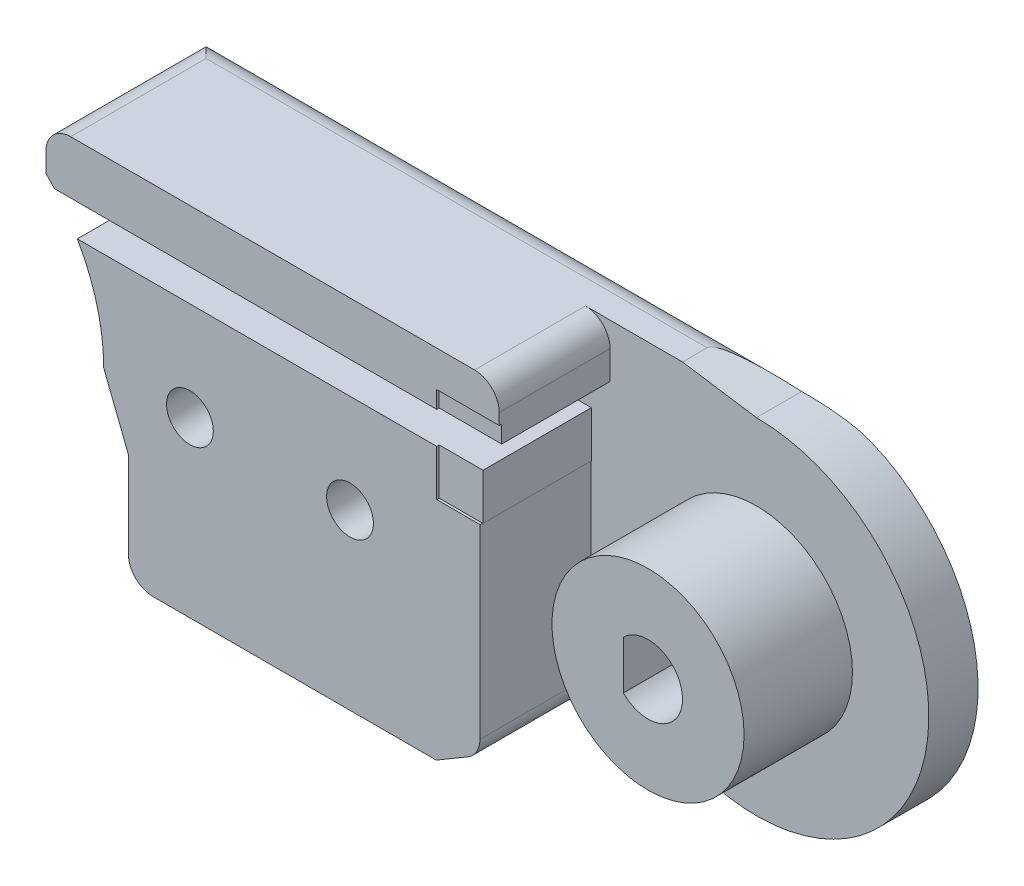
from build123d import *

# Parameters (mm, degrees)
BOSS_EXTRUDE1_DEPTH  = 2
BOSS_EXTRUDE6_DEPTH  = 4.5
CUT_EXTRUDE6_DEPTH   = 4.5
BOSS_EXTRUDE14_DEPTH = 2.3
SKETCH32_R           = 3
CUT_EXTRUDE7_DEPTH   = 2.3
SKETCH33_W           = 17.343145750507624
SKETCH33_H           = 2
BOSS_EXTRUDE15_DEPTH = 1.2
CUT_EXTRUDE8_DEPTH   = 2.4
CUT_EXTRUDE9_DEPTH   = 4.3999999999999995
SKETCH37_R           = 3.899999999999994
BOSS_EXTRUDE16_DEPTH = 4.4
CUT_EXTRUDE10_DEPTH  = 39.60291748102272
SKETCH43_R           = 2.5000000000000004
SKETCH43_R_2         = 2.4999999999999982
BOSS_EXTRUDE17_DEPTH = 1.2
SKETCH44_R           = 0.9499999999999992
SKETCH44_R_2         = 0.9500000000000008
CUT_EXTRUDE11_DEPTH  = 40.360198653546576
SKETCH45_R           = 1.9999999999999996
SKETCH45_R_2         = 2.000000000000003
CUT_EXTRUDE12_DEPTH  = 4.5
SKETCH49_R           = 0.7500000000000021
CUT_EXTRUDE13_DEPTH  = 3
CUT_EXTRUDE14_DEPTH  = 6.8
FILLET1_R            = 1.5
FILLET3_R            = 1


with BuildPart() as part:
    # Sketch3 → Boss-Extrude1 (new body)
    with BuildSketch(Plane.XY):
        with BuildLine():
            Line((8.000000000000002, 0), (8.999999999999993, -2.5431457505076343))
            Line((8.999999999999993, -2.5431457505076343), (8.999999999999993, -7.04314575050762))
            Line((8.999999999999993, -7.04314575050762), (21.50000000000003, -7.043145750507617))
            Line((21.50000000000003, -7.043145750507617), (25.05025253169419, -4.949747468305846))
            ThreePointArc((25.05025253169419, -4.949747468305846), (36.46715672757901, -2.678784026555599), (30, 7.000000000000014))
            Line((30, 7.000000000000014), (26.999999999999996, 7.456854249492377))
            Line((26.999999999999996, 7.456854249492377), (5.656854249492369, 7.456854249492377))
            Line((5.656854249492369, 7.456854249492377), (5.656854249492376, 5.656854249492382))
            ThreePointArc((5.656854249492376, 5.656854249492382), (7.391036260090296, 3.061467458920721), (8.000000000000002, 0))
        make_face()
    extrude(amount=BOSS_EXTRUDE1_DEPTH)

    # Sketch22 → Boss-Extrude6 (add)
    with BuildSketch(Plane.XY.offset(2)):
        with BuildLine():
            Line((5.656854249492376, 7.456854249492377), (21.50000000000004, 7.456854249492377))
            Line((21.50000000000004, 7.456854249492377), (26.999999999999996, 7.456854249492377))
            Line((26.999999999999996, 7.456854249492377), (26.999999999999996, 2.1288604946885763))
            Line((26.999999999999996, 2.1288604946885763), (23.27512626584711, 2.128860494688576))
            Line((23.27512626584711, 2.128860494688576), (23.27512626584711, -5.996446609406731))
            Line((23.27512626584711, -5.996446609406731), (21.50000000000003, -7.043145750507617))
            Line((21.50000000000003, -7.043145750507617), (8.999999999999993, -7.04314575050762))
            Line((8.999999999999993, -7.04314575050762), (8.999999999999993, -2.5431457505076343))
            Line((8.999999999999993, -2.5431457505076343), (7.999999999999998, 0))
            ThreePointArc((7.999999999999998, 0), (7.391036260090291, 3.061467458920719), (5.656854249492376, 5.656854249492382))
            Line((5.656854249492376, 5.656854249492382), (5.656854249492376, 7.456854249492377))
        make_face()
    extrude(amount=BOSS_EXTRUDE6_DEPTH)

    # Sketch26 → Cut-Extrude6 (cut)
    with BuildSketch(Plane.XY.offset(2)):
        Polygon((18.098080447707712, 5.299999999999999), (2.5300524575164793, 5.299999999999999), (2.5300524575164793, 4), (18.098080447707712, 4), (26.999999999999996, 4), (26.999999999999996, 5.299999999999999), align=None)
    extrude(amount=CUT_EXTRUDE6_DEPTH, mode=Mode.SUBTRACT)


with BuildPart() as body_2:
    # Sketch31 → Boss-Extrude14 (new body)
    with BuildSketch(Plane.XY.offset(6.5)):
        with BuildLine():
            Line((2.4326880657739025, 5.656854249492382), (0, 5.656854249492382))
            ThreePointArc((0, 5.656854249492382), (-5.656854249492382, 6.9e-16), (0, -5.656854249492382))
            Line((0, -5.656854249492382), (9.000000000000004, -5.656854249492382))
            Line((9.000000000000004, -5.656854249492382), (8.999999999999993, -7.04314575050762))
            Line((8.999999999999993, -7.04314575050762), (8.999999999999993, -8.54314575050762))
            Line((8.999999999999993, -8.54314575050762), (21.50000000000003, -8.54314575050762))
            Line((21.50000000000003, -8.54314575050762), (21.50000000000003, -7.043145750507617))
            Line((21.50000000000003, -7.043145750507617), (23.27512626584711, -5.996446609406731))
            Line((23.27512626584711, -5.996446609406731), (23.27512626584711, 2.128860494688576))
            Line((23.27512626584711, 2.128860494688576), (26.999999999999996, 2.1288604946885763))
            Line((26.999999999999996, 2.1288604946885763), (26.999999999999996, 7.456854249492377))
            Line((26.999999999999996, 7.456854249492377), (26.999999999999996, 8.956854249492377))
            Line((26.999999999999996, 8.956854249492377), (5.656854249492376, 8.956854249492377))
            Line((5.656854249492376, 8.956854249492377), (5.656854249492376, 7.456854249492377))
            Line((5.656854249492376, 7.456854249492377), (5.656854249492376, 5.656854249492382))
            Line((5.656854249492376, 5.656854249492382), (2.4326880657739025, 5.656854249492382))
        make_face()
    extrude(amount=BOSS_EXTRUDE14_DEPTH)

    # Sketch32 → Cut-Extrude7 (cut)
    with BuildSketch(Plane.XY.offset(8.799999999999999)):
        Circle(SKETCH32_R)
    extrude(amount=-CUT_EXTRUDE7_DEPTH, mode=Mode.SUBTRACT)

    # Sketch33 → Boss-Extrude15 (add)
    with BuildSketch(Plane.XY.offset(8.799999999999999)):
        with Locations((14.328427124746185, 7.956854249492377)):
            Rectangle(SKETCH33_W, SKETCH33_H)
        Polygon((9.000000000000004, -7.043145750507619), (9.000000000000004, -8.54314575050762), (21.50000000000003, -8.54314575050762), (21.50000000000003, -7.043145750507617), align=None)
        with BuildLine():
            Line((7.000000000000003, -4.156854249492383), (23.275126265847117, -4.156854249492383))
            Line((23.275126265847117, -4.156854249492383), (23.275126265847113, -2.1568542494923815))
            Line((23.275126265847113, -2.1568542494923815), (7.000000000000003, -2.1568542494923832))
            ThreePointArc((7.000000000000003, -2.1568542494923832), (6.000000000000003, -3.1568542494923832), (7.000000000000003, -4.156854249492383))
        make_face()
        with BuildLine():
            Line((18.999999999999996, 2.172006245196199), (7.000000000000003, 2.172006245196201))
            ThreePointArc((7.000000000000003, 2.172006245196201), (6.0000000000000036, 3.1720062451962), (7.000000000000003, 4.172006245196199))
            Line((7.000000000000003, 4.172006245196199), (18.999999999999996, 4.172006245196199))
            Line((18.999999999999996, 4.172006245196199), (18.999999999999996, 2.172006245196199))
        make_face()
    extrude(amount=BOSS_EXTRUDE15_DEPTH)


with BuildPart() as cut_extrude8_tool:
    # Sketch35 → Cut-Extrude8 (new body)
    with BuildSketch(Plane.XY.offset(8.799999999999999)):
        Polygon((26.999999999999996, 2.1288604946885763), (26.999999999999996, 6.000000000000002), (21.520354003499165, 6.000000000000002), (21.520354003499165, 2.1288604946885754), align=None)
    extrude(amount=-CUT_EXTRUDE8_DEPTH)


with BuildPart() as part_1:
    add(part.part)

    # Cut-Extrude8: cut by cut_extrude8_tool
    add(cut_extrude8_tool.part, mode=Mode.SUBTRACT)

    # Sketch36 → Cut-Extrude9 (cut)
    with BuildSketch(Plane.XY.offset(6.3999999999999995)):
        Polygon((26.999999999999996, 2.1288604946885763), (26.999999999999996, 4), (23.30000000000004, 3.999999999999999), (23.30000000000003, 2.1288604946885754), align=None)
    extrude(amount=-CUT_EXTRUDE9_DEPTH, mode=Mode.SUBTRACT)

    # Sketch37 → Boss-Extrude16 (add)
    with BuildSketch(Plane.XY.offset(2)):
        with Locations((29.999999999999996, 1.388e-14)):
            Circle(SKETCH37_R)
    extrude(amount=BOSS_EXTRUDE16_DEPTH)

    # Sketch39 → Cut-Extrude10 (cut, through all)
    with BuildSketch(Plane.XY.offset(6.4)):
        with BuildLine():
            Line((28.999999999999993, 0.9797958971132569), (28.999999999999993, -0.9797958971132569))
            ThreePointArc((28.999999999999993, -0.9797958971132569), (31.4, 2.383e-14), (28.999999999999993, 0.9797958971132569))
        make_face()
    extrude(amount=-CUT_EXTRUDE10_DEPTH, mode=Mode.SUBTRACT)


with BuildPart() as body_2_1:
    add(body_2.part)

    # Cut-Extrude8: cut by cut_extrude8_tool
    add(cut_extrude8_tool.part, mode=Mode.SUBTRACT)

    # Sketch43 → Boss-Extrude17 (add)
    with BuildSketch(Plane.XY.offset(8.799999999999999)):
        with Locations((11.500000000000004, 0)):
            Circle(SKETCH43_R)
        with Locations((18.000000000000004, 0)):
            Circle(SKETCH43_R_2)
    extrude(amount=BOSS_EXTRUDE17_DEPTH)


with BuildPart() as cut_extrude11_tool:
    # Sketch44 → Cut-Extrude11 (new, through all)
    with BuildSketch(Plane.XY.offset(9.999999999999998)):
        with Locations((11.500000000000004, 0)):
            Circle(SKETCH44_R)
        with Locations((18.000000000000004, 0)):
            Circle(SKETCH44_R_2)
    extrude(amount=-CUT_EXTRUDE11_DEPTH)


with BuildPart() as part_2:
    add(part_1.part)

    # Cut-Extrude11: cut by cut_extrude11_tool
    add(cut_extrude11_tool.part, mode=Mode.SUBTRACT)

    # Sketch45 → Cut-Extrude12 (cut)
    with BuildSketch(Plane(origin=(0, 0, 0), x_dir=(-1, 0, 0), z_dir=(0, 0, -1))):
        with Locations((-11.500000000000004, 0)):
            Circle(SKETCH45_R)
        with Locations((-18.000000000000004, 0)):
            Circle(SKETCH45_R_2)
    extrude(amount=-CUT_EXTRUDE12_DEPTH, mode=Mode.SUBTRACT)


with BuildPart() as body_2_2:
    add(body_2_1.part)

    # Cut-Extrude11: cut by cut_extrude11_tool
    add(cut_extrude11_tool.part, mode=Mode.SUBTRACT)

    # Sketch49 → Cut-Extrude13 (cut)
    with BuildSketch(Plane.XZ.offset(-6.956854249492377)):
        with Locations((19.999999999999996, 9.999999999999998)):
            Circle(SKETCH49_R)
    extrude(amount=-CUT_EXTRUDE13_DEPTH, mode=Mode.SUBTRACT)


with BuildPart() as cut_extrude14_tool:
    # Sketch51 → Cut-Extrude14 (new body)
    with BuildSketch(Plane.XY.offset(8.799999999999999)):
        Polygon((27, 8.956854249492377), (24.058650564533934, 8.956854249492377), (24.058650564533938, 4.991269007681976), (26.999999999999996, 4.991269007681976), align=None)
    extrude(amount=-CUT_EXTRUDE14_DEPTH)


with BuildPart() as part_3:
    add(part_2.part)

    # Cut-Extrude14: cut by cut_extrude14_tool
    add(cut_extrude14_tool.part, mode=Mode.SUBTRACT)

    # Fillet3
    fillet3_edges = [part_3.edges().sort_by_distance(p)[0] for p in [
        (23.27512626584711, -5.996446609406731, 4.25),
        (24.058650564533934, 7.456854249492377, 4.25),
        (8.999999999999993, -7.04314575050762, 3.25),
        (5.656854249492373, 7.456854249492377, 3.25),
        (15.25000000000001, -7.043145750507618, 0),
        (16.328427124746185, 7.456854249492377, 0),
    ]]
    fillet(fillet3_edges, radius=FILLET3_R)


with BuildPart() as body_2_3:
    add(body_2_2.part)

    # Cut-Extrude14: cut by cut_extrude14_tool
    add(cut_extrude14_tool.part, mode=Mode.SUBTRACT)

    # Fillet1
    fillet1_edges = [body_2_3.edges().sort_by_distance(p)[0] for p in [
        (14.857752407013155, 8.956854249492377, 6.5),
        (15.25000000000001, -8.54314575050762, 6.5),
    ]]
    fillet(fillet1_edges, radius=FILLET1_R)


solid = part_3.part
